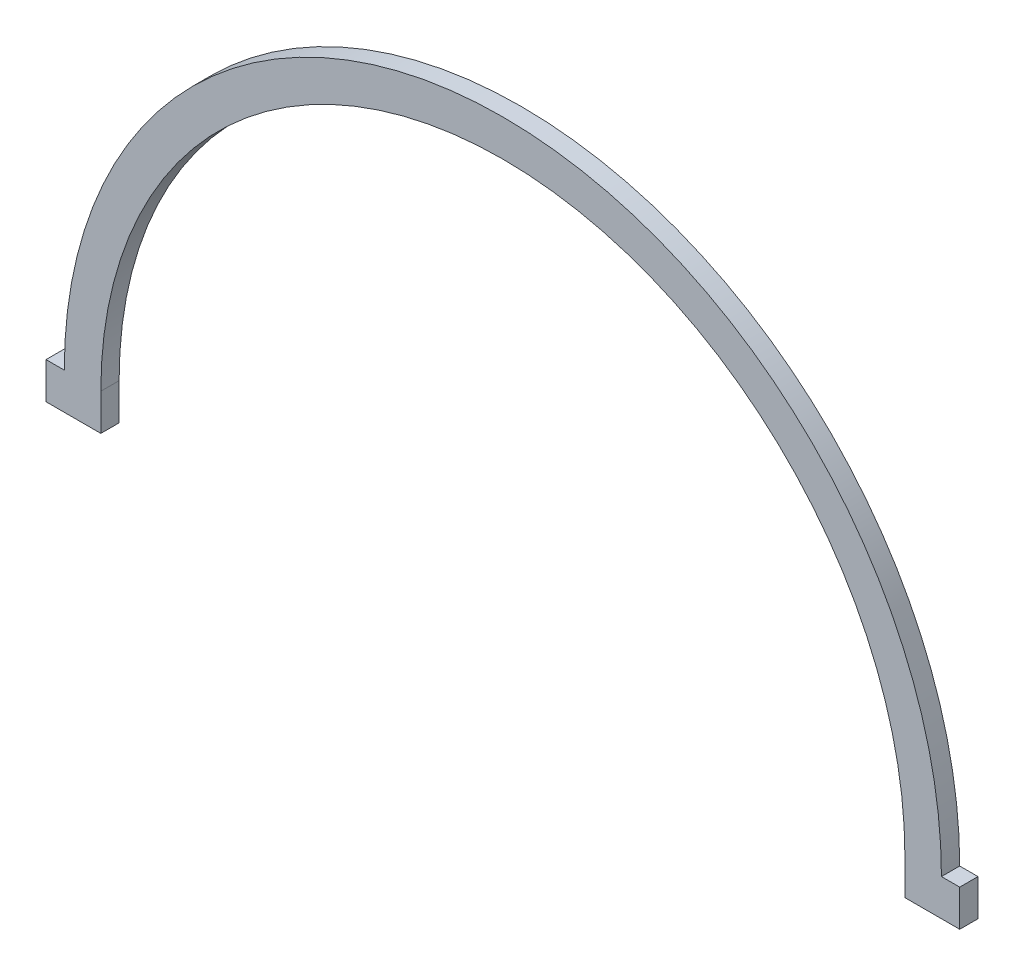
from build123d import *

# Parameters (mm, degrees)
BOSS_EXTRUDE1_DEPTH = 3.175
SKETCH2_W           = 139.682423128
SKETCH2_H           = 6.35
CUT_EXTRUDE1_DEPTH  = 4.175


with BuildPart() as part:
    # Sketch1 → Boss-Extrude1 (new body)
    with BuildSketch(Plane.XY):
        with BuildLine():
            Line((76.2, 0), (79.375, 0))
            Line((79.375, 0), (79.375, -6.35))
            Line((79.375, -6.35), (-79.375, -6.35))
            Line((-79.375, -6.35), (-79.375, 0))
            Line((-79.375, 0), (-76.2, 0))
            ThreePointArc((-76.2, 0), (0, 76.2), (76.2, 0))
        make_face()
        with BuildLine():
            Line((-69.85, 0), (69.85, 0))
            ThreePointArc((69.85, 0), (0, 69.85), (-69.85, 0))
        make_face(mode=Mode.SUBTRACT)
    extrude(amount=BOSS_EXTRUDE1_DEPTH)

    # Sketch2 → Cut-Extrude1 (cut, through all)
    with BuildSketch(Plane.XY.offset(3.175)):
        with Locations((-0.008788436, -3.175)):
            Rectangle(SKETCH2_W, SKETCH2_H)
    extrude(amount=-CUT_EXTRUDE1_DEPTH, mode=Mode.SUBTRACT)


solid = part.part
